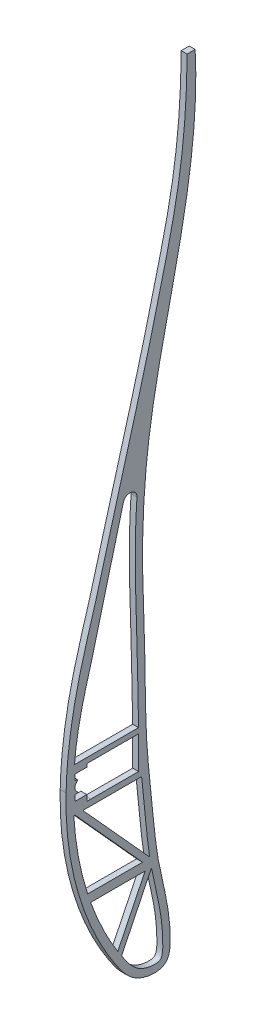
from build123d import *

# Parameters (mm, degrees)
BOSS_EXTRUDE6_DEPTH = 2


with BuildPart() as part:
    # Sketch6 → Boss-Extrude6 (new body)
    with BuildSketch(Plane(origin=(0, 0, 0), x_dir=(0, 0, -1), z_dir=(1, 0, 0))):
        with BuildLine():
            add(Edge.make_bspline(
                [(591.451949682, 376.641580619), (590.872388848, 355.683165934), (598.012688593, 330.746988511), (614.723651598, 309.091270023), (626.400178816, 308.094359763), (627.187788502, 324.007406453), (622.17411364, 339.246671451), (620.513458687, 359.78765193), (618.195038142, 380.006793486), (618.340163692, 403.830289977), (616.749939927, 433.356418179), (618.959185324, 474.521327111), (631.646475046, 520.190754683), (636.017672553, 556.341703047), (635.097952039, 572.591500862)],
                knots=[0, 0, 0, 0, 0.181752607, 0.211103075, 0.236631639, 0.255743147, 0.327686462, 0.385847508, 0.430345594, 0.504499374, 0.591378164, 0.686470872, 0.859585878, 1, 1, 1, 1], degree=3))
            Line((635.097952039, 572.591500862), (632.37665032, 572.591500862))
            add(Edge.make_bspline(
                [(632.37665032, 572.591500862), (632.330961932, 559.797001866), (630.75176347, 538.472848259), (623.645443325, 509.584711707), (617.10863586, 483.615922335), (609.187778041, 456.429195327), (602.627705324, 431.109316673), (594.458107799, 405.002169681), (591.69057219, 387.726063657), (591.451949682, 376.641580619)],
                knots=[0, 0, 0, 0, 0.191350507, 0.317516473, 0.443871056, 0.591483171, 0.740452737, 0.834547041, 1, 1, 1, 1], degree=3))
        make_face()
        with BuildLine():
            Line((618.175640549, 340.390577854), (609.000646846, 321.588616515))
            Line((609.000646846, 321.588616515), (608.930960215, 321.445810384))
            add(Edge.make_bspline(
                [(599.756260285, 340.390577852), (599.788214133, 340.301108432), (600.418798067, 338.543441214), (601.743581468, 335.153970586), (603.939923775, 330.321343942), (606.333319555, 325.742025629), (608.062553003, 322.824333795), (608.930960215, 321.445810384)],
                knots=[0.108517756, 0.108517756, 0.108517756, 0.108517756, 0.109355307, 0.124980653, 0.140605998, 0.156231344, 0.170688244, 0.170688244, 0.170688244, 0.170688244], degree=3))
            Line((599.756260285, 340.390577852), (618.175640549, 340.390577854))
        make_face(mode=Mode.SUBTRACT)
        with BuildLine():
            Line((594.058132817, 368.641580619), (594.432640457, 368.641580619))
            Line((594.432640457, 368.641580619), (617.311789075, 343.390577854))
            Line((617.311789075, 343.390577854), (598.738178232, 343.390577854))
            add(Edge.make_bspline(
                [(594.058132817, 368.641580619), (594.105663214, 367.767257096), (594.403593404, 363.373479382), (595.471546921, 355.469180835), (597.307671139, 347.962509935), (598.547688932, 343.982527817), (598.738178232, 343.390577854)],
                knots=[0.023466467, 0.023466467, 0.023466467, 0.023466467, 0.03122858, 0.062479271, 0.093729962, 0.099209786, 0.099209786, 0.099209786, 0.099209786], degree=3))
        make_face(mode=Mode.SUBTRACT)
        with BuildLine():
            Line((597.131500115, 368.641580619), (617.000191215, 368.641580619))
            add(Edge.make_bspline(
                [(619.723897475, 343.707056274), (619.588065425, 344.584237151), (619.202246602, 347.27320119), (618.676364911, 351.798595651), (618.14434935, 357.276455548), (617.61793723, 362.687518014), (617.218553524, 366.469205269), (617.018688127, 368.456625281), (617.000191215, 368.641580619)],
                knots=[0.336109592, 0.336109592, 0.336109592, 0.336109592, 0.34373549, 0.359360835, 0.374986181, 0.390611526, 0.406236872, 0.407839817, 0.407839817, 0.407839817, 0.407839817], degree=3))
            Line((619.723897475, 343.707056274), (597.131500115, 368.641580619))
        make_face(mode=Mode.SUBTRACT)
        with BuildLine():
            Line((615.991740163, 381.694414184), (615.991740163, 380.641580619))
            Line((615.991740163, 380.641580619), (615.991740163, 370.613174516))
            Line((615.991740163, 370.613174516), (599.756260285, 370.643337268))
            Line((599.756260285, 370.643337268), (598.451949682, 370.643337268))
            Line((598.451949682, 370.643337268), (598.451949682, 372.641580619))
            Line((598.451949682, 372.641580619), (594.451949682, 372.641580619))
            Line((594.451949682, 372.641580619), (594.451949682, 374.641580619))
            Line((594.451949682, 374.641580619), (595.187038618, 374.641580619))
            ThreePointArc((595.187038618, 374.641580619), (595.377731135, 374.78127835), (595.302030533, 375.005216983))
            ThreePointArc((595.302030533, 375.005216983), (594.451949682, 376.641580619), (595.302030533, 378.277944256))
            ThreePointArc((595.302030533, 378.277944256), (595.377731135, 378.501882888), (595.187038618, 378.641580619))
            Line((595.187038618, 378.641580619), (594.451949682, 378.641580619))
            Line((594.451949682, 378.641580619), (594.451949682, 380.641580619))
            Line((594.451949682, 380.641580619), (598.451949682, 380.641580619))
            Line((598.451949682, 380.641580619), (598.451949682, 381.694414184))
            Line((598.451949682, 381.694414184), (599.756260285, 381.694414184))
            Line((599.756260285, 381.694414184), (615.991740163, 381.694414184))
        make_face(mode=Mode.SUBTRACT)
        with BuildLine():
            add(Edge.make_bspline(
                [(615.960239376, 383.484006723), (615.883915664, 385.61862146), (615.747907328, 391.385122418), (615.664183638, 400.734707645), (615.34152061, 411.50750606), (614.949882146, 422.347237667), (614.747152851, 433.249362089), (614.931573311, 442.918431524), (615.253624545, 448.937124327), (615.414589942, 451.3047764)],
                knots=[0.45040628, 0.45040628, 0.45040628, 0.45040628, 0.468738254, 0.499988945, 0.531239635, 0.562490326, 0.593741017, 0.624991708, 0.645292841, 0.645292841, 0.645292841, 0.645292841], degree=3))
            Line((615.960239376, 383.484006723), (594.276061182, 383.484006723))
            add(Edge.make_bspline(
                [(610.872473345, 452.251745912), (610.269005103, 449.892967281), (608.899761049, 444.675822661), (606.737063351, 436.629422515), (604.522241225, 428.077866992), (602.357777204, 419.486101285), (600.05733403, 410.876322417), (597.594520531, 402.389753087), (595.610315955, 393.890955055), (594.657705913, 387.548922178), (594.326590544, 384.073552739), (594.276061182, 383.484006723)],
                knots=[0.448611114, 0.448611114, 0.448611114, 0.448611114, 0.500019032, 0.562521411, 0.62502379, 0.687526169, 0.750028548, 0.812530927, 0.875033306, 0.937535685, 0.950297268, 0.950297268, 0.950297268, 0.950297268], degree=3))
            ThreePointArc((610.872473345, 452.251745912), (613.538756498, 453.673947709), (615.414589942, 451.3047764))
        make_face(mode=Mode.SUBTRACT)
        with BuildLine():
            Line((610.200194857, 319.486333617), (610.798059213, 320.711514022))
            Line((610.798059213, 320.711514022), (620.321147624, 340.22681241))
            add(Edge.make_bspline(
                [(610.200194857, 319.486333617), (610.329238139, 319.292273197), (610.94758865, 318.369232226), (612.074999665, 316.741572171), (613.593830136, 314.877496332), (615.267971518, 313.362305554), (617.190260663, 312.22883236), (619.697083128, 311.461156033), (621.720905583, 311.36042338), (622.841363248, 311.592264418), (623.335468961, 311.850989533), (623.497272441, 312.003684935), (623.773431987, 312.479839107), (624.012199505, 313.372750522), (624.191514478, 314.954836637), (624.175383225, 317.405665059), (624.026751297, 320.200934873), (623.746858801, 322.903834088), (623.364672196, 325.530514516), (622.900595426, 328.105854239), (622.203217923, 331.500756755), (621.295577506, 335.483611247), (620.608621672, 338.710824577), (620.321147624, 340.22681241)],
                knots=[0.177597421, 0.177597421, 0.177597421, 0.177597421, 0.179669362, 0.187482035, 0.195294708, 0.20310738, 0.210920053, 0.218732726, 0.226545399, 0.230451735, 0.234358071, 0.238264408, 0.242170744, 0.24607708, 0.249983417, 0.257796089, 0.265608762, 0.273421435, 0.281234108, 0.28904678, 0.296859453, 0.312484799, 0.32593146, 0.32593146, 0.32593146, 0.32593146], degree=3))
        make_face(mode=Mode.SUBTRACT)
    extrude(amount=BOSS_EXTRUDE6_DEPTH)


solid = part.part
